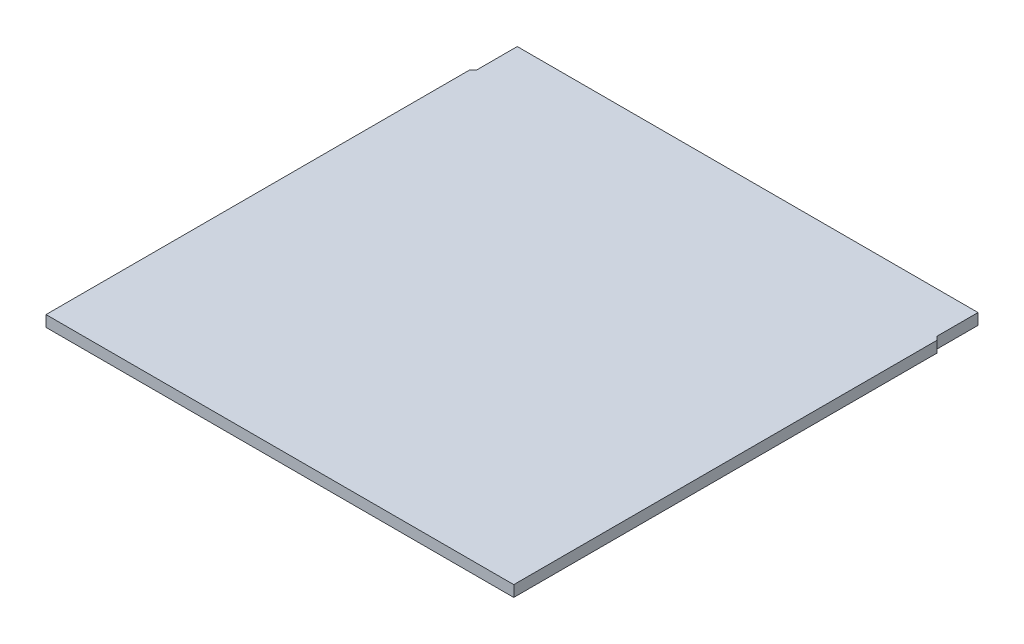
from build123d import *

# Parameters (mm, degrees)
SKETCH1_W           = 400
SKETCH1_H           = 400
BOSS_EXTRUDE1_DEPTH = 9.525
CUT_EXTRUDE1_DEPTH  = 10.525


with BuildPart() as part:
    # Sketch1 → Boss-Extrude1 (new body)
    with BuildSketch(Plane(origin=(0, 0, 0), x_dir=(1, 0, 0), z_dir=(0, 1, 0))):
        Rectangle(SKETCH1_W, SKETCH1_H)
    extrude(amount=BOSS_EXTRUDE1_DEPTH)

    # Sketch2 → Cut-Extrude1 (cut, through all)
    with BuildSketch(Plane(origin=(0, 9.525, 0), x_dir=(1, 0, 0), z_dir=(0, 1, 0))):
        Polygon((197, 200), (197, 165), (200, 162), (200, 200), align=None)
    cut_extrude1 = extrude(amount=-CUT_EXTRUDE1_DEPTH, mode=Mode.SUBTRACT)

    # Mirror1: Cut-Extrude1 across plane
    add(cut_extrude1.mirror(Plane(origin=(0, 0, 0), x_dir=(0, 0, 1), z_dir=(1, 0, 0))), mode=Mode.SUBTRACT)


solid = part.part
